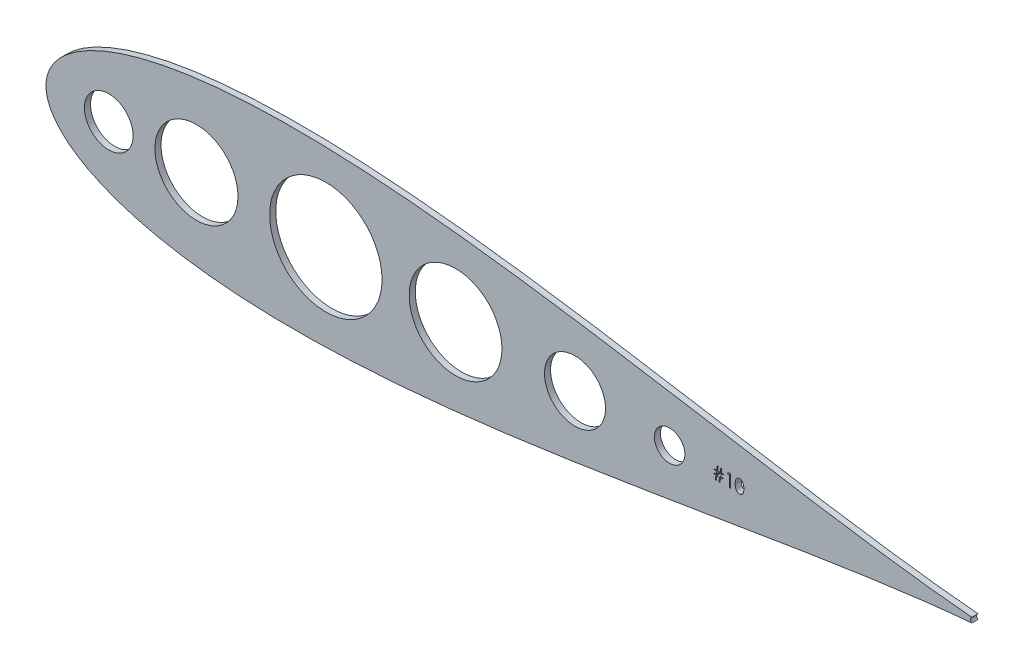
from build123d import *

# Parameters (mm, degrees)
SKETCH2_R           = 10.130056053
SKETCH2_R_2         = 6.35
SKETCH2_R_3         = 12.7
SKETCH2_R_4         = 19.300769349
SKETCH2_R_5         = 23.378357794
SKETCH2_R_6         = 17.272
BOSS_EXTRUDE1_DEPTH = 2.54


with BuildPart() as part:
    # Sketch2 → Boss-Extrude1 (new body)
    with BuildSketch(Plane.XY):
        with BuildLine():
            ThreePointArc((733.094458589, 571.145233343), (732.545217897, 570.114105972), (733.092625489, 569.082004271))
            add(Edge.make_bspline(
                [(733.094458589, 571.145233343), (731.071708037, 571.317921944), (726.773768323, 571.715269774), (719.930993216, 572.427098506), (712.334872672, 573.301658873), (704.022402008, 574.343315633), (695.032362487, 575.553129378), (685.403631288, 576.928387748), (675.177904294, 578.461986944), (664.398604914, 580.143017226), (653.110892108, 581.956469163), (641.361413459, 583.883612287), (629.198169585, 585.902229126), (616.670358597, 587.98684052), (603.828293671, 590.10916185), (590.723320288, 592.238442601), (577.407772952, 594.341970434), (563.934946828, 596.385512076), (550.35909561, 598.333920975), (536.735425172, 600.151583235), (523.120106966, 601.803052389), (509.570287351, 603.253558862), (496.144096325, 604.469623955), (482.900641975, 605.419548215), (469.900009328, 606.074004196), (457.203247278, 606.406588245), (444.872347821, 606.39424081), (432.970266907, 606.017374444), (421.560925424, 605.261233674), (410.709394946, 604.114853717), (400.482000776, 602.573067108), (390.946941922, 600.635333008), (382.174754121, 598.308135436), (374.239597628, 595.605113532), (367.220633365, 592.550351675), (361.203098109, 589.184301712), (356.276891114, 585.575270729), (352.524964086, 581.841134841), (349.984849518, 578.179330061), (348.568410846, 574.875654104), (347.996426137, 572.225488819), (347.866151466, 570.113697054), (347.996426137, 568.001905288), (348.568410846, 565.351740003), (349.984849518, 562.048064047), (352.524964086, 558.386259267), (356.276891114, 554.652123378), (361.203098109, 551.043092395), (367.220633365, 547.677042433), (374.239597628, 544.622280575), (382.174754121, 541.919258671), (390.946941922, 539.5920611), (400.482000776, 537.654326999), (410.709394946, 536.11254039), (421.560925424, 534.966160433), (432.970266907, 534.210019663), (444.872347821, 533.833153298), (457.203247278, 533.820805862), (469.900009328, 534.153389912), (482.900641975, 534.807845892), (496.144096325, 535.757770153), (509.570287351, 536.973835246), (523.120106966, 538.424341719), (536.735425172, 540.075810873), (550.35909561, 541.893473132), (563.934946828, 543.841882032), (577.407772952, 545.885423673), (590.723320288, 547.988951506), (603.828293671, 550.118232257), (616.670358597, 552.240553587), (629.198169585, 554.325164982), (641.361413459, 556.343781821), (653.110892108, 558.270924944), (664.398604914, 560.084376881), (675.177904294, 561.765407163), (685.403631288, 563.299006359), (695.032362487, 564.674264729), (704.022402008, 565.884078475), (712.334872672, 566.925735235), (719.930993216, 567.800295602), (726.773159483, 568.512060998), (731.070491643, 568.909359706), (733.092625489, 569.082004271)],
                knots=[0.021301255, 0.021301255, 0.021301255, 0.021301255, 0.028552555, 0.036780684, 0.045920102, 0.055931764, 0.066772884, 0.07839713, 0.090754827, 0.103793165, 0.117456432, 0.131686226, 0.146421738, 0.161599998, 0.177156133, 0.193023668, 0.209134786, 0.225420633, 0.241811602, 0.258237647, 0.274628557, 0.290914287, 0.307025229, 0.322892517, 0.338448342, 0.353626207, 0.368361232, 0.382590428, 0.396252961, 0.409290412, 0.42164701, 0.433269881, 0.444109249, 0.45411864, 0.463255055, 0.471479114, 0.478755289, 0.485052318, 0.490344026, 0.494609833, 0.497833231, 0.5, 0.502166769, 0.505390167, 0.509655974, 0.514947682, 0.521244711, 0.528520886, 0.536744945, 0.54588136, 0.555890751, 0.566730119, 0.57835299, 0.590709588, 0.603747039, 0.617409572, 0.631638768, 0.646373793, 0.661551658, 0.677107483, 0.692974771, 0.709085713, 0.725371443, 0.741762353, 0.758188398, 0.774579367, 0.790865214, 0.806976332, 0.822843867, 0.838400002, 0.853578262, 0.868313774, 0.882543568, 0.896206835, 0.909245173, 0.92160287, 0.933227116, 0.944068236, 0.954079898, 0.963219316, 0.971447445, 0.978696555, 0.978696555, 0.978696555, 0.978696555], degree=3))
        make_face()
        with Locations((374.009106824, 570.113000193)):
            Circle(SKETCH2_R, mode=Mode.SUBTRACT)
        with Locations((607.341644578, 570.113000193)):
            Circle(SKETCH2_R_2, mode=Mode.SUBTRACT)
        with Locations((567.971644578, 570.113000193)):
            Circle(SKETCH2_R_3, mode=Mode.SUBTRACT)
        with Locations((518.28807379, 570.113000193)):
            Circle(SKETCH2_R_4, mode=Mode.SUBTRACT)
        with Locations((464.324110405, 570.113000193)):
            Circle(SKETCH2_R_5, mode=Mode.SUBTRACT)
        with Locations((410.491644578, 570.113697058)):
            Circle(SKETCH2_R_6, mode=Mode.SUBTRACT)
        Polygon((632.183407482, 567.317924585), (632.183407482, 572.066856209), (631.36930492, 572.066856209), (631.679893529, 572.609591248), (632.658300645, 572.609591248), (632.658300645, 567.317924585), align=None, mode=Mode.SUBTRACT)
        Polygon((629.673257918, 570.710018598), (628.759512588, 570.710018598), (628.577187537, 569.488864759), (629.537574156, 569.488864759), (629.537574156, 569.149655348), (628.526306125, 569.149655348), (628.25175851, 567.317924585), (627.841527144, 567.317924585), (628.116074758, 569.149655348), (627.033784762, 569.149655348), (626.759237147, 567.317924585), (626.349005781, 567.317924585), (626.623553385, 569.149655348), (625.738428856, 569.149655348), (625.738428856, 569.488864759), (626.674434797, 569.488864759), (626.857819881, 570.710018598), (625.874112618, 570.710018598), (625.874112618, 571.049227998), (626.908701293, 571.049227998), (627.163108343, 572.74527501), (627.572279687, 572.74527501), (627.317872626, 571.049227998), (628.401222657, 571.049227998), (628.655629707, 572.74527501), (629.06480105, 572.74527501), (628.810394, 571.049227998), (629.673257918, 571.049227998), align=None, mode=Mode.SUBTRACT)
        with BuildLine():
            add(Edge.make_bspline(
                [(638.221334837, 569.961637859), (638.220349703, 569.880714807), (638.21843021, 569.723039542), (638.208483832, 569.492427234), (638.188891616, 569.274715907), (638.164383657, 569.069383422), (638.13043994, 568.877284403), (638.088703557, 568.697754106), (638.042363188, 568.530017235), (637.985160583, 568.375447937), (637.922551533, 568.231889975), (637.854432367, 568.097833691), (637.781452987, 567.972094177), (637.701943813, 567.855677893), (637.617196391, 567.747760162), (637.525396877, 567.650245899), (637.429133016, 567.560785478), (637.327211864, 567.481181232), (637.220756304, 567.411505396), (637.111961033, 567.34919398), (636.998895679, 567.29894931), (636.884122525, 567.255807045), (636.765999876, 567.222846838), (636.644674976, 567.200056605), (636.520764952, 567.184072976), (636.437003062, 567.182853656), (636.394904215, 567.182240823)],
                knots=[0, 0, 0, 0, 0.06506329, 0.126773166, 0.185515763, 0.240764679, 0.292979796, 0.342250373, 0.388919286, 0.432775664, 0.474628433, 0.514774691, 0.553605893, 0.591426406, 0.62802812, 0.663803634, 0.698984336, 0.733591489, 0.767628469, 0.801208348, 0.83426384, 0.866980695, 0.899719742, 0.932701912, 0.966175883, 1, 1, 1, 1], degree=3))
            add(Edge.make_bspline(
                [(636.394904215, 567.182240823), (636.353169423, 567.182945908), (636.270876561, 567.184336198), (636.148937775, 567.198720054), (636.030582176, 567.221845399), (635.915225726, 567.254225264), (635.80227659, 567.2938596), (635.693273871, 567.345496717), (635.587005588, 567.404966083), (635.483755259, 567.472692494), (635.385463063, 567.550285991), (635.291575886, 567.63610819), (635.204452345, 567.732300728), (635.1233627, 567.837344731), (635.046294734, 567.9502738), (634.975402467, 568.072629792), (634.909829866, 568.203927549), (634.849892684, 568.345015342), (634.796751252, 568.497951959), (634.749810074, 568.664487027), (634.712747003, 568.846090429), (634.681022773, 569.041303591), (634.655434718, 569.250965367), (634.637965678, 569.475189579), (634.62716869, 569.713836502), (634.626208524, 569.877530089), (634.625715179, 569.961637859)],
                knots=[0, 0, 0, 0, 0.033787146, 0.066621658, 0.099284878, 0.131361165, 0.163585188, 0.196103927, 0.228902254, 0.262158056, 0.295991222, 0.330217846, 0.365059826, 0.400950737, 0.437620382, 0.475707529, 0.515380692, 0.556413541, 0.59976483, 0.646424156, 0.696431445, 0.749781518, 0.806573307, 0.867435532, 0.931886753, 1, 1, 1, 1], degree=3))
            add(Edge.make_bspline(
                [(634.625715179, 569.961637859), (634.626211111, 570.046451766), (634.627174467, 570.211204004), (634.637891484, 570.451271261), (634.65569468, 570.676485031), (634.680092851, 570.886856095), (634.709783607, 571.082438763), (634.749418926, 571.26271036), (634.794493044, 571.428505241), (634.846733051, 571.580364053), (634.905678875, 571.720332723), (634.969835436, 571.850999396), (635.041748875, 571.972166365), (635.117309208, 572.085767549), (635.199575078, 572.189943373), (635.286205392, 572.286165017), (635.380581324, 572.372208652), (635.479494682, 572.450595323), (635.583841003, 572.519310596), (635.690645986, 572.579836284), (635.800644777, 572.631543226), (635.914137697, 572.672199004), (636.030104659, 572.705779689), (636.148951058, 572.728743932), (636.27087312, 572.743193067), (636.353168265, 572.744574446), (636.394904215, 572.745275011)],
                knots=[0, 0, 0, 0, 0.068594622, 0.133246042, 0.194312586, 0.251279223, 0.304513439, 0.354234907, 0.400480589, 0.443410755, 0.484014869, 0.523252301, 0.561042373, 0.597900239, 0.633518489, 0.668314351, 0.702495671, 0.736685354, 0.770293169, 0.803437255, 0.835912952, 0.868460246, 0.900846538, 0.933466525, 0.966257575, 1, 1, 1, 1], degree=3))
            add(Edge.make_bspline(
                [(636.394904215, 572.745275011), (636.436988807, 572.744537481), (636.520681821, 572.743070766), (636.644416674, 572.728973853), (636.765292978, 572.705582988), (636.882795402, 572.672440562), (636.997889132, 572.631323289), (637.109673938, 572.579786815), (637.218844169, 572.519796146), (637.323664961, 572.449305284), (637.425287058, 572.370713033), (637.521214335, 572.281869474), (637.611455525, 572.183671684), (637.697143189, 572.077170295), (637.775846294, 571.960322607), (637.850796602, 571.835160917), (637.917882895, 571.699496396), (637.982493654, 571.555592593), (638.038263264, 571.399467776), (638.088558659, 571.232002007), (638.1291971, 571.051217224), (638.163047547, 570.858061949), (638.189271378, 570.651826825), (638.20837073, 570.432953943), (638.218459799, 570.201299305), (638.220359811, 570.042915414), (638.221334837, 569.961637859)],
                knots=[0, 0, 0, 0, 0.033788116, 0.067193932, 0.099862411, 0.132566612, 0.165151173, 0.197913187, 0.231319004, 0.265083278, 0.299255309, 0.334398567, 0.369942824, 0.406283561, 0.44406382, 0.482997707, 0.523354447, 0.56553659, 0.609612924, 0.656390811, 0.705885495, 0.7583245, 0.813831783, 0.872794559, 0.93472223, 1, 1, 1, 1], degree=3))
        make_face(mode=Mode.SUBTRACT)
    extrude(amount=BOSS_EXTRUDE1_DEPTH)


solid = part.part
